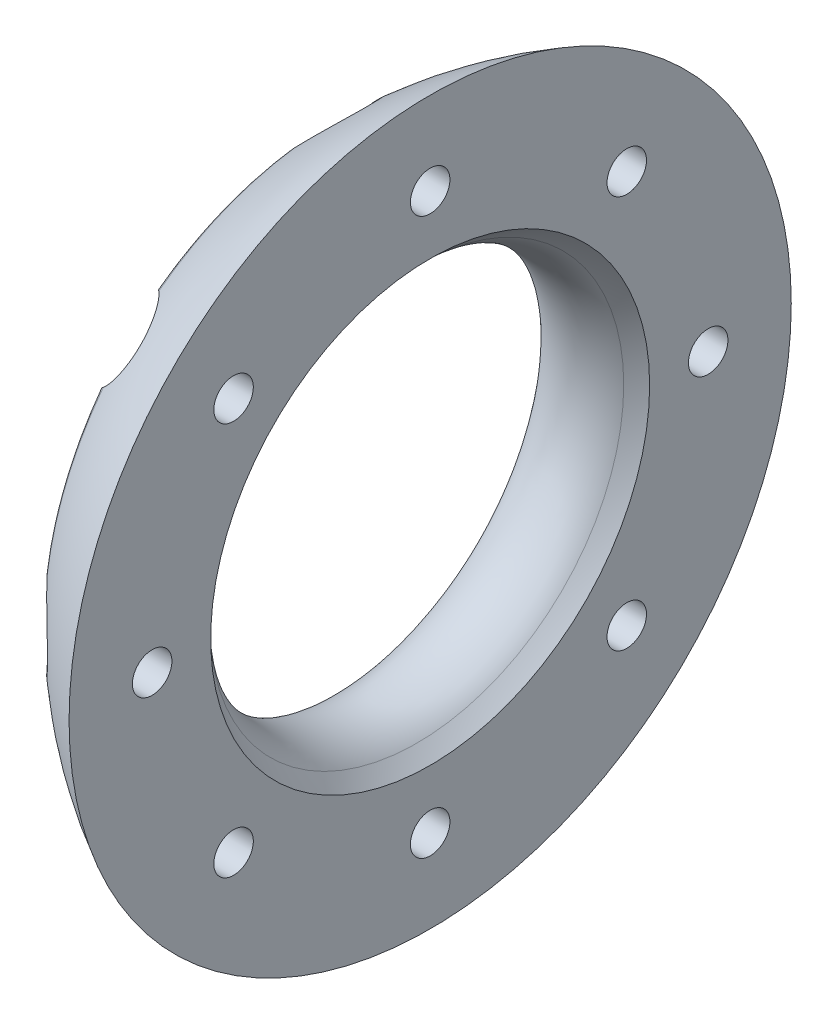
from build123d import *

# Parameters (mm, degrees)
KREISMUSTER1_COUNT = 8


with BuildPart() as part:
    # Skizze1 → Rotation1 (revolve)
    with BuildSketch(Plane(origin=(0, 0, 0), x_dir=(1, 0, 0), z_dir=(0, 1, 0))):
        with BuildLine():
            Line((-13.228756555, 15), (-13.228756555, 24.677925359))
            ThreePointArc((-13.228756555, 24.677925359), (-16.693082741, 22.479790671), (-19.798989873, 19.798989873))
            ThreePointArc((-19.798989873, 19.798989873), (-19.798989873, 14.142135624), (-14.142135624, 14.142135624))
            ThreePointArc((-14.142135624, 14.142135624), (-13.692166282, 14.578222886), (-13.228756555, 15))
        make_face()
    revolve(axis=Axis((0, 0, 0), (-1, 0, 0)))

    # Skizze2 → Schnitt-Rotation1 (revolve, cut)
    with BuildSketch(Plane.XY):
        Polygon((-13.228756555, 19), (-13.228756555, 20.35), (-15.228756555, 20.35), (-15.228756555, 21.75), (-23.228756555, 21.75), (-23.228756555, 19), align=None)
    schnitt_rotation1 = revolve(axis=Axis((-23.228756555, 19, 0), (1, 0, 0)), mode=Mode.SUBTRACT)

    # Kreismuster1: Schnitt-Rotation1 ×8 about axis
    kreismuster1_axis = Axis((-23.728756555, 0, 0), (1, 0, 0))
    for i in range(1, KREISMUSTER1_COUNT):
        add(schnitt_rotation1.rotate(kreismuster1_axis, i * 360 / KREISMUSTER1_COUNT), mode=Mode.SUBTRACT)


solid = part.part
